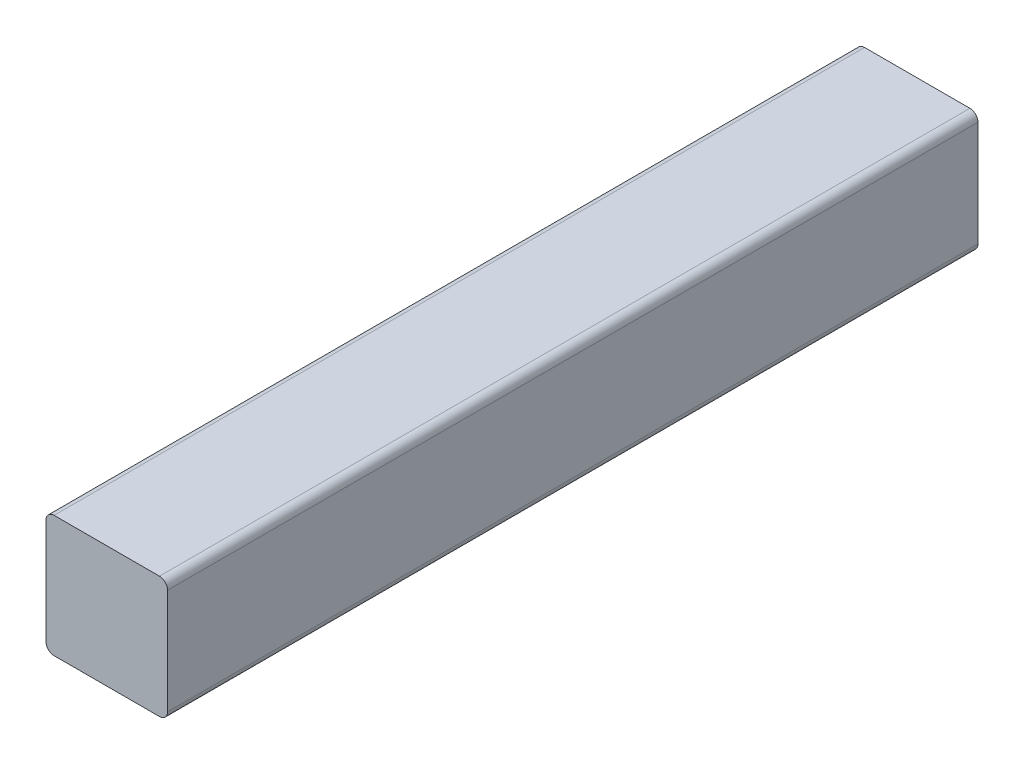
from build123d import *

# Parameters (mm, degrees)
BOSS_EXTRUDE1_DEPTH = 200


with BuildPart() as part:
    # Sketch3 → Boss-Extrude1 (new body)
    with BuildSketch(Plane.XY):
        with BuildLine():
            Line((2, 0), (28, 0))
            ThreePointArc((28, 0), (29.414213562, 0.585786438), (30, 2))
            Line((30, 2), (30, 28))
            ThreePointArc((30, 28), (29.414213562, 29.414213562), (28, 30))
            Line((28, 30), (2, 30))
            ThreePointArc((2, 30), (0.585786438, 29.414213562), (0, 28))
            Line((0, 28), (0, 2))
            ThreePointArc((0, 2), (0.585786438, 0.585786438), (2, 0))
        make_face()
    extrude(amount=BOSS_EXTRUDE1_DEPTH)


solid = part.part
